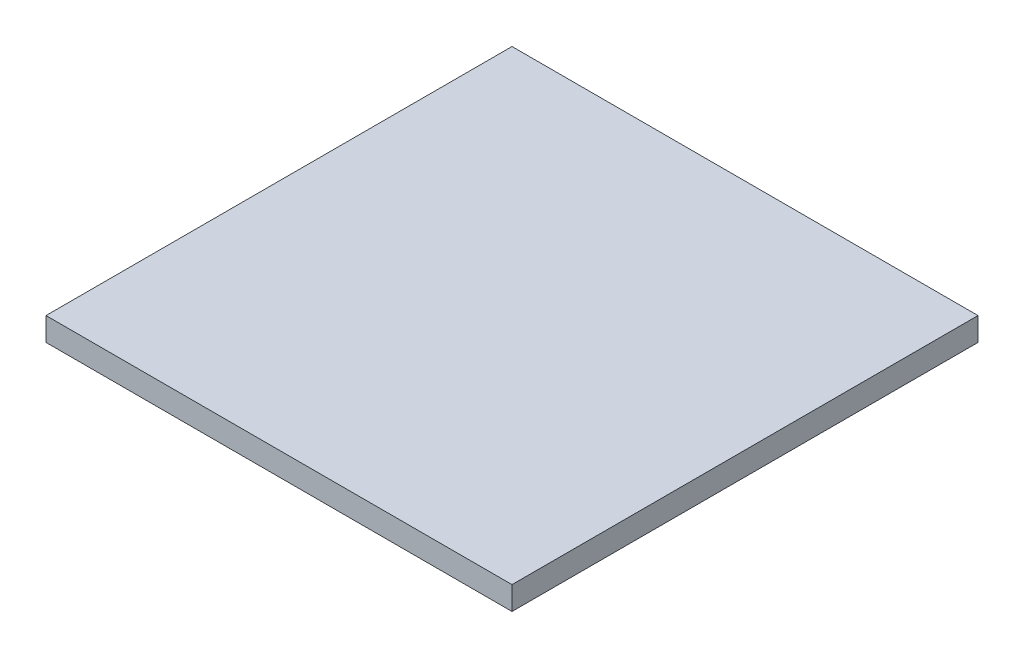
from build123d import *

# Parameters (mm, degrees)
SKETCH_1_W      = 200
SKETCH_1_H      = 200
EXTRUDE_1_DEPTH = 10


with BuildPart() as part:
    # Эскиз1 → Бобышка-Вытянуть1 (new body)
    with BuildSketch(Plane(origin=(0, 0, 0), x_dir=(1, 0, 0), z_dir=(0, 1, 0))):
        Rectangle(SKETCH_1_W, SKETCH_1_H)
    extrude(amount=EXTRUDE_1_DEPTH)


solid = part.part
